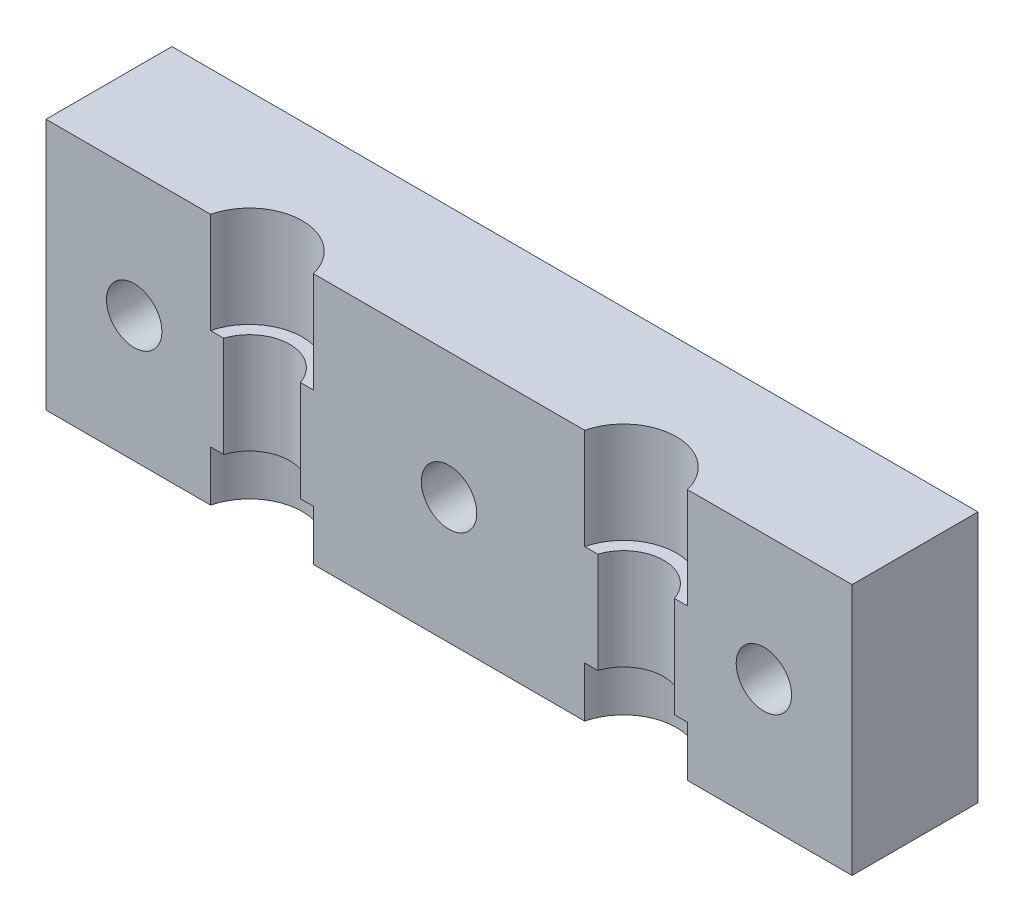
from build123d import *

# Parameters (mm, degrees)
SKETCH_1_W          = 32
SKETCH_1_H          = 10
EXTRUDE_1_DEPTH     = 5
SKETCH_2_R          = 2.1
CUT_EXTRUDE_1_DEPTH = 11
EXTRUDE_2_DEPTH     = 4
SKETCH_5_R          = 1.1
CUT_EXTRUDE_2_DEPTH = 6
CUT_EXTRUDE_3_DEPTH = 1.6


with BuildPart() as part:
    # Эскиз1 → Бобышка-Вытянуть1 (new body)
    with BuildSketch(Plane.XY):
        with Locations((16, 5)):
            Rectangle(SKETCH_1_W, SKETCH_1_H)
    extrude(amount=EXTRUDE_1_DEPTH)

    # Эскиз2 → Вырез-Вытянуть1 (cut, through all)
    with BuildSketch(Plane(origin=(0, 10, 0), x_dir=(1, 0, 0), z_dir=(0, 1, 0))):
        with Locations((8.575, -5.5)):
            Circle(SKETCH_2_R)
        with Locations((23.425, -5.5)):
            Circle(SKETCH_2_R)
    extrude(amount=-CUT_EXTRUDE_1_DEPTH, mode=Mode.SUBTRACT)

    # Эскиз4 → Бобышка-Вытянуть2 (add)
    with BuildSketch(Plane.XZ.offset(-6)):
        with BuildLine():
            Line((6.535392195, 5), (7.055131585, 5))
            ThreePointArc((7.055131585, 5), (8.575, 3.9), (10.094868415, 5))
            Line((10.094868415, 5), (10.614607805, 5))
            ThreePointArc((10.614607805, 5), (8.575, 3.4), (6.535392195, 5))
        make_face()
        with BuildLine():
            Line((21.385392195, 5), (21.905131585, 5))
            ThreePointArc((21.905131585, 5), (23.425, 3.9), (24.944868415, 5))
            Line((24.944868415, 5), (25.464607805, 5))
            ThreePointArc((25.464607805, 5), (23.425, 3.4), (21.385392195, 5))
        make_face()
    extrude(amount=EXTRUDE_2_DEPTH)

    # Эскиз5 → Вырез-Вытянуть2 (cut, through all)
    with BuildSketch(Plane(origin=(0, 0, 0), x_dir=(-1, 0, 0), z_dir=(0, 0, -1))):
        with Locations((-3.5, 5)):
            Circle(SKETCH_5_R)
        with Locations((-16, 5)):
            Circle(SKETCH_5_R)
        with Locations((-28.5, 5)):
            Circle(SKETCH_5_R)
    extrude(amount=-CUT_EXTRUDE_2_DEPTH, mode=Mode.SUBTRACT)

    # Эскиз6 → Вырез-Вытянуть3 (cut)
    with BuildSketch(Plane(origin=(0, 0, 0), x_dir=(-1, 0, 0), z_dir=(0, 0, -1))):
        Polygon((-16, 2.575128869), (-13.9, 3.787564435), (-13.9, 6.212435565), (-16, 7.424871131), (-18.1, 6.212435565), (-18.1, 3.787564435), align=None)
        Polygon((-3.5, 2.575128869), (-1.4, 3.787564435), (-1.4, 6.212435565), (-3.5, 7.424871131), (-5.6, 6.212435565), (-5.6, 3.787564435), align=None)
        Polygon((-28.5, 2.575128869), (-26.4, 3.787564435), (-26.4, 6.212435565), (-28.5, 7.424871131), (-30.6, 6.212435565), (-30.6, 3.787564435), align=None)
    extrude(amount=-CUT_EXTRUDE_3_DEPTH, mode=Mode.SUBTRACT)


solid = part.part
